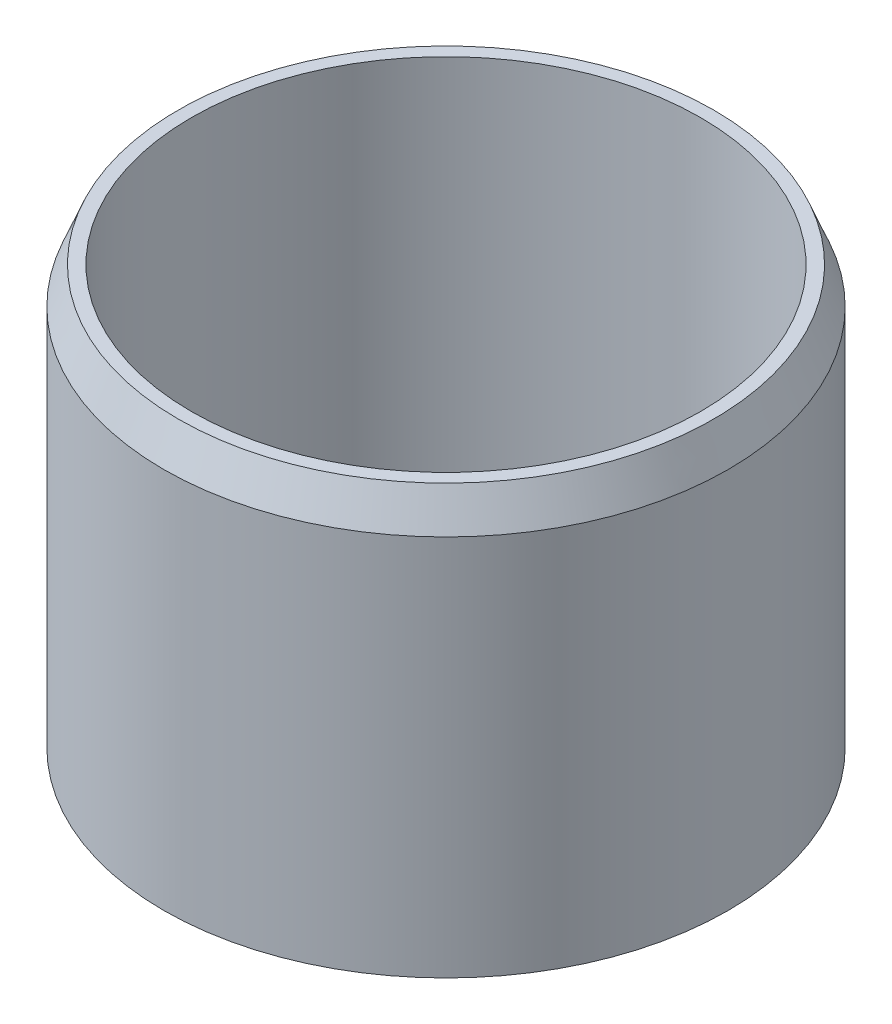
from build123d import *

# Parameters (mm, degrees)
SKETCH1_R           = 49.276
SKETCH1_R_2         = 6.5024
SKETCH1_R_3         = 12.7
BOSS_EXTRUDE1_DEPTH = 9.525
SKETCH2_R           = 49.276
SKETCH2_R_2         = 44.45
BOSS_EXTRUDE2_DEPTH = 63.5
SKETCH3_R           = 12.7
SKETCH3_R_2         = 6.5024
BOSS_EXTRUDE3_DEPTH = 15.875
CHAMFER1_SIZE       = 6.35
CHAMFER1_SIZE2      = 2.54
SKETCH4_R           = 12.7
BOSS_EXTRUDE4_DEPTH = 6.35
FILLET1_R           = 2.54


with BuildPart() as part:
    # Sketch1 → Boss-Extrude1 (new body)
    with BuildSketch(Plane(origin=(0, 0, 0), x_dir=(1, 0, 0), z_dir=(0, 1, 0))):
        Circle(SKETCH1_R)
        Circle(SKETCH1_R_2, mode=Mode.SUBTRACT)
        with Locations((0, 28.575)):
            Circle(SKETCH1_R_3, mode=Mode.SUBTRACT)
        with Locations((27.176439953, 8.830160614)):
            Circle(SKETCH1_R_3, mode=Mode.SUBTRACT)
        with Locations((16.795963584, -23.117660614)):
            Circle(SKETCH1_R_3, mode=Mode.SUBTRACT)
        with Locations((-16.795963584, -23.117660614)):
            Circle(SKETCH1_R_3, mode=Mode.SUBTRACT)
        with Locations((-27.176439953, 8.830160614)):
            Circle(SKETCH1_R_3, mode=Mode.SUBTRACT)
    extrude(amount=BOSS_EXTRUDE1_DEPTH)

    # Sketch2 → Boss-Extrude2 (add)
    with BuildSketch(Plane(origin=(0, 9.525, 0), x_dir=(1, 0, 0), z_dir=(0, 1, 0))):
        Circle(SKETCH2_R)
        Circle(SKETCH2_R_2, mode=Mode.SUBTRACT)
    extrude(amount=BOSS_EXTRUDE2_DEPTH)

    # Sketch3 → Boss-Extrude3 (add)
    with BuildSketch(Plane(origin=(0, 9.525, 0), x_dir=(1, 0, 0), z_dir=(0, 1, 0))):
        Circle(SKETCH3_R)
        Circle(SKETCH3_R_2, mode=Mode.SUBTRACT)
    extrude(amount=BOSS_EXTRUDE3_DEPTH)

    # Chamfer1
    chamfer1_edges = [part.edges().sort_by_distance(p)[0] for p in [
        (-49.276, 73.025, 0),
    ]]
    chamfer1_side = [part.faces().sort_by_distance(p)[0] for p in [
        (-49.276, 36.5125, 0),
    ]]
    chamfer(chamfer1_edges, length=CHAMFER1_SIZE, length2=CHAMFER1_SIZE2, reference=chamfer1_side[0])

    # Sketch4 → Boss-Extrude4 (add)
    with BuildSketch(Plane(origin=(0, 25.4, 0), x_dir=(1, 0, 0), z_dir=(0, 1, 0))):
        Circle(SKETCH4_R)
    extrude(amount=BOSS_EXTRUDE4_DEPTH)

    # Fillet1
    fillet1_edges = [part.edges().sort_by_distance(p)[0] for p in [
        (-12.7, 31.75, 0),
    ]]
    fillet(fillet1_edges, radius=FILLET1_R)


solid = part.part
